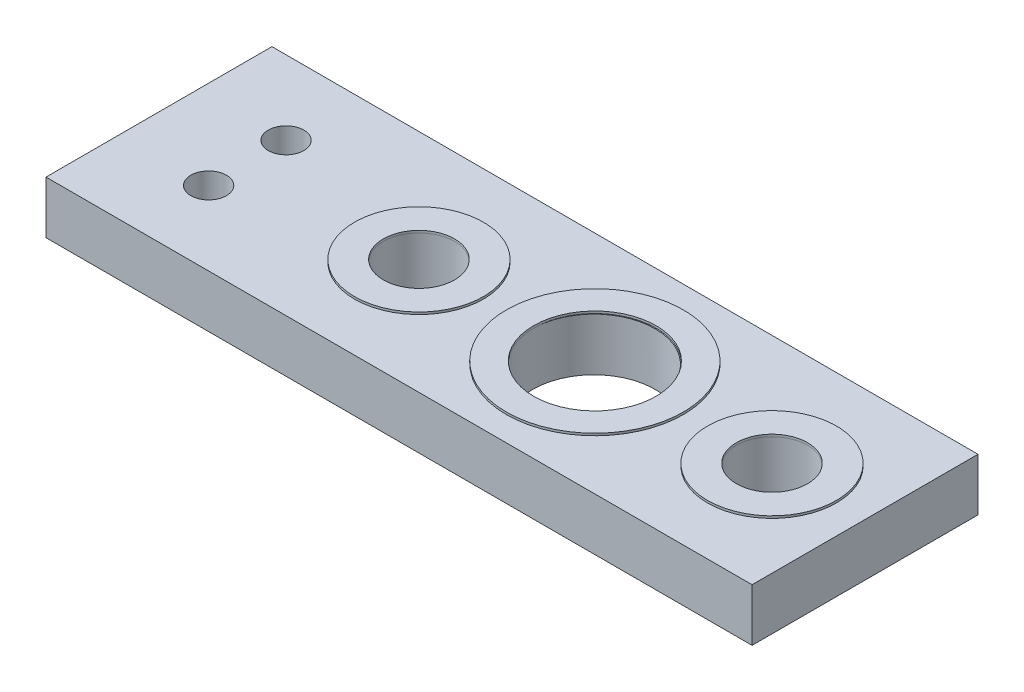
from build123d import *

# Parameters (mm, degrees)
SKETCH4_W           = 31.75
SKETCH4_H           = 10.16
SKETCH4_R           = 1.60011781
SKETCH4_R_2         = 2.752866622
SKETCH4_R_3         = 0.8
BOSS_EXTRUDE2_DEPTH = 2.3622
SKETCH6_R           = 2.899
SKETCH6_R_2         = 1.60011781
SKETCH6_R_3         = 3.98
SKETCH6_R_4         = 2.75286662
BOSS_EXTRUDE4_DEPTH = 0.1


with BuildPart() as part:
    # Sketch4 → Boss-Extrude2 (new body)
    with BuildSketch(Plane(origin=(0, 0, 0), x_dir=(1, 0, 0), z_dir=(0, 1, 0))):
        with Locations((20.174102355, 12.093517689)):
            Rectangle(SKETCH4_W, SKETCH4_H)
        with Locations((31.864642323, 12.093517689)):
            Circle(SKETCH4_R, mode=Mode.SUBTRACT)
        with Locations((23.900817311, 12.049817479)):
            Circle(SKETCH4_R_2, mode=Mode.SUBTRACT)
        with Locations((15.989642323, 12.093517689)):
            Circle(SKETCH4_R, mode=Mode.SUBTRACT)
        with Locations((8.266142573, 13.842017689)):
            Circle(SKETCH4_R_3, mode=Mode.SUBTRACT)
        with Locations((8.281059155, 10.345049502)):
            Circle(SKETCH4_R_3, mode=Mode.SUBTRACT)
    extrude(amount=BOSS_EXTRUDE2_DEPTH)

    # Sketch6 → Boss-Extrude4 (add)
    with BuildSketch(Plane(origin=(0, 2.3622, 0), x_dir=(1, 0, 0), z_dir=(0, 1, 0))):
        with Locations((31.865102355, 12.093517689)):
            Circle(SKETCH6_R)
        with Locations((31.865102355, 12.093517689)):
            Circle(SKETCH6_R_2, mode=Mode.SUBTRACT)
        with Locations((15.990102355, 12.093517689)):
            Circle(SKETCH6_R)
        with Locations((15.990102355, 12.093517689)):
            Circle(SKETCH6_R_2, mode=Mode.SUBTRACT)
        with Locations((23.901102355, 12.093517689)):
            Circle(SKETCH6_R_3)
        with Locations((23.901102355, 12.093517689)):
            Circle(SKETCH6_R_4, mode=Mode.SUBTRACT)
    extrude(amount=BOSS_EXTRUDE4_DEPTH)


solid = part.part
